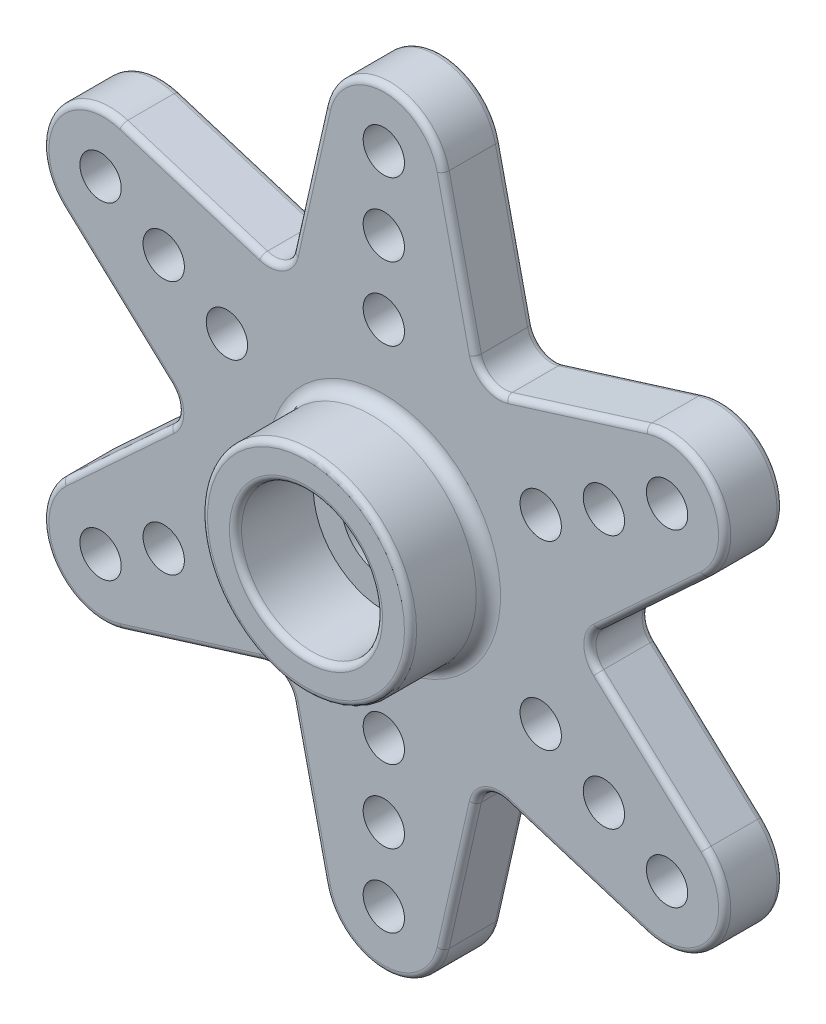
from build123d import *

# Parameters (mm, degrees)
SKETCH1_R                    = 1.75
BOSS_EXTRUDE1_DEPTH          = 2.4
SKETCH2_R                    = 4.3
SKETCH2_R_2                  = 2.9
BOSS_EXTRUDE2_DEPTH          = 3.2
SKETCH4_R                    = 3.6
SKETCH4_R_2                  = 3.3
BOSS_EXTRUDE3_DEPTH          = 0.2
SKETCH5_R                    = 4
SKETCH5_R_2                  = 3.6
SKETCH5_R_3                  = 3.3
CUT_EXTRUDE2_DEPTH           = 0.4
SKETCH6_R                    = 0.85
CUT_EXTRUDE3_DEPTH           = 22.851960767
LPATTERN1_COUNT              = 3
LPATTERN1_PITCH              = 3
CIRPATTERN1_COUNT            = 6
CIRPATTERN1_COPY_1_SKETCH_R  = 0.85
CIRPATTERN1_COPY_1_DEPTH     = 22.851960767
CIRPATTERN1_COPY_2_SKETCH_R  = 0.85
CIRPATTERN1_COPY_2_DEPTH     = 22.851960767
CIRPATTERN1_COPY_3_SKETCH_R  = 0.85
CIRPATTERN1_COPY_3_DEPTH     = 22.851960767
CIRPATTERN1_COPY_4_SKETCH_R  = 0.85
CIRPATTERN1_COPY_4_DEPTH     = 22.851960767
CIRPATTERN1_COPY_5_SKETCH_R  = 0.85
CIRPATTERN1_COPY_5_DEPTH     = 22.851960767
CIRPATTERN1_COPY_6_SKETCH_R  = 0.85
CIRPATTERN1_COPY_6_DEPTH     = 22.851960767
CIRPATTERN1_COPY_7_SKETCH_R  = 0.85
CIRPATTERN1_COPY_7_DEPTH     = 22.851960767
CIRPATTERN1_COPY_8_SKETCH_R  = 0.85
CIRPATTERN1_COPY_8_DEPTH     = 22.851960767
CIRPATTERN1_COPY_9_SKETCH_R  = 0.85
CIRPATTERN1_COPY_9_DEPTH     = 22.851960767
CIRPATTERN1_COPY_10_SKETCH_R = 0.85
CIRPATTERN1_COPY_10_DEPTH    = 22.851960767
FILLET3_R                    = 1
FILLET1_R                    = 0.25
FILLET2_R                    = 0.5


with BuildPart() as part:
    # Sketch1 → Boss-Extrude1 (new body)
    with BuildSketch(Plane.XY):
        with BuildLine():
            Line((-4, -6.92820323), (-2.438733851, -13.850070181))
            ThreePointArc((-2.438733851, -13.850070181), (0, -15.8), (2.438733851, -13.850070181))
            Line((2.438733851, -13.850070181), (4, -6.92820323))
            Line((4, -6.92820323), (10.775145696, -9.037040559))
            ThreePointArc((10.775145696, -9.037040559), (13.68320138, -7.9), (13.213879547, -4.813029623))
            Line((13.213879547, -4.813029623), (8, 0))
            Line((8, 0), (13.213879547, 4.813029623))
            ThreePointArc((13.213879547, 4.813029623), (13.68320138, 7.9), (10.775145696, 9.037040559))
            Line((10.775145696, 9.037040559), (4, 6.92820323))
            Line((4, 6.92820323), (2.438733851, 13.850070181))
            ThreePointArc((2.438733851, 13.850070181), (0, 15.8), (-2.438733851, 13.850070181))
            Line((-2.438733851, 13.850070181), (-4, 6.92820323))
            Line((-4, 6.92820323), (-10.775145696, 9.037040559))
            ThreePointArc((-10.775145696, 9.037040559), (-13.68320138, 7.9), (-13.213879547, 4.813029623))
            Line((-13.213879547, 4.813029623), (-8, 0))
            Line((-8, 0), (-13.213879547, -4.813029623))
            ThreePointArc((-13.213879547, -4.813029623), (-13.68320138, -7.9), (-10.775145696, -9.037040559))
            Line((-10.775145696, -9.037040559), (-4, -6.92820323))
        make_face()
        Circle(SKETCH1_R, mode=Mode.SUBTRACT)
    extrude(amount=BOSS_EXTRUDE1_DEPTH)

    # Sketch2 → Boss-Extrude2 (add)
    with BuildSketch(Plane.XY.offset(2.4)):
        with Locations(Location((0, 0, 0), (0, 0, 180))):
            Circle(SKETCH2_R)
        Circle(SKETCH2_R_2, mode=Mode.SUBTRACT)
    extrude(amount=BOSS_EXTRUDE2_DEPTH)

    # Sketch4 → Boss-Extrude3 (add)
    with BuildSketch(Plane(origin=(0, 0, 0), x_dir=(-1, 0, 0), z_dir=(0, 0, -1))):
        Circle(SKETCH4_R)
        Circle(SKETCH4_R_2, mode=Mode.SUBTRACT)
    extrude(amount=BOSS_EXTRUDE3_DEPTH)

    # Sketch5 → Cut-Extrude2 (cut)
    with BuildSketch(Plane(origin=(0, 0, 0), x_dir=(-1, 0, 0), z_dir=(0, 0, -1))):
        Circle(SKETCH5_R)
        Circle(SKETCH5_R_2, mode=Mode.SUBTRACT)
        Circle(SKETCH5_R_3)
    extrude(amount=-CUT_EXTRUDE2_DEPTH, mode=Mode.SUBTRACT)

    # Sketch6 → Cut-Extrude3 (cut, through all)
    with BuildSketch(Plane(origin=(0, 0, 0), x_dir=(-1, 0, 0), z_dir=(0, 0, -1))):
        with Locations((0, 7.45)):
            Circle(SKETCH6_R)
    cut_extrude3 = extrude(amount=-CUT_EXTRUDE3_DEPTH, mode=Mode.SUBTRACT)

    # LPattern1: Cut-Extrude3 ×3
    with Locations(*[(0, i * LPATTERN1_PITCH, 0) for i in range(1, LPATTERN1_COUNT)]):
        add(cut_extrude3, mode=Mode.SUBTRACT)

    # CirPattern1: Cut-Extrude3 ×6 about axis
    cirpattern1_axis = Axis((0, 0, 0), (0, 0, 1))
    for i in range(1, CIRPATTERN1_COUNT):
        add(cut_extrude3.rotate(cirpattern1_axis, i * 360 / CIRPATTERN1_COUNT), mode=Mode.SUBTRACT)

    # CirPattern1 copy 1 sketch → CirPattern1 copy 1 (cut, through all)
    with BuildSketch(Plane(origin=(-2.598076211, 1.5, 0), x_dir=(-0.5000000000000001, -0.8660254037844386, 0), z_dir=(0, 0, -1))):
        with Locations((0, 7.45)):
            Circle(CIRPATTERN1_COPY_1_SKETCH_R)
    extrude(amount=-CIRPATTERN1_COPY_1_DEPTH, mode=Mode.SUBTRACT)

    # CirPattern1 copy 2 sketch → CirPattern1 copy 2 (cut, through all)
    with BuildSketch(Plane(origin=(-2.598076211, -1.5, 0), x_dir=(0.4999999999999998, -0.8660254037844387, 0), z_dir=(0, 0, -1))):
        with Locations((0, 7.45)):
            Circle(CIRPATTERN1_COPY_2_SKETCH_R)
    extrude(amount=-CIRPATTERN1_COPY_2_DEPTH, mode=Mode.SUBTRACT)

    # CirPattern1 copy 3 sketch → CirPattern1 copy 3 (cut, through all)
    with BuildSketch(Plane(origin=(0, -3, 0), x_dir=(1, 0, 0), z_dir=(0, 0, -1))):
        with Locations((0, 7.45)):
            Circle(CIRPATTERN1_COPY_3_SKETCH_R)
    extrude(amount=-CIRPATTERN1_COPY_3_DEPTH, mode=Mode.SUBTRACT)

    # CirPattern1 copy 4 sketch → CirPattern1 copy 4 (cut, through all)
    with BuildSketch(Plane(origin=(2.598076211, -1.5, 0), x_dir=(0.5000000000000004, 0.8660254037844384, 0), z_dir=(0, 0, -1))):
        with Locations((0, 7.45)):
            Circle(CIRPATTERN1_COPY_4_SKETCH_R)
    extrude(amount=-CIRPATTERN1_COPY_4_DEPTH, mode=Mode.SUBTRACT)

    # CirPattern1 copy 5 sketch → CirPattern1 copy 5 (cut, through all)
    with BuildSketch(Plane(origin=(2.598076211, 1.5, 0), x_dir=(-0.5000000000000001, 0.8660254037844386, 0), z_dir=(0, 0, -1))):
        with Locations((0, 7.45)):
            Circle(CIRPATTERN1_COPY_5_SKETCH_R)
    extrude(amount=-CIRPATTERN1_COPY_5_DEPTH, mode=Mode.SUBTRACT)

    # CirPattern1 copy 6 sketch → CirPattern1 copy 6 (cut, through all)
    with BuildSketch(Plane(origin=(-5.196152423, 3, 0), x_dir=(-0.5000000000000001, -0.8660254037844386, 0), z_dir=(0, 0, -1))):
        with Locations((0, 7.45)):
            Circle(CIRPATTERN1_COPY_6_SKETCH_R)
    extrude(amount=-CIRPATTERN1_COPY_6_DEPTH, mode=Mode.SUBTRACT)

    # CirPattern1 copy 7 sketch → CirPattern1 copy 7 (cut, through all)
    with BuildSketch(Plane(origin=(-5.196152423, -3, 0), x_dir=(0.4999999999999998, -0.8660254037844387, 0), z_dir=(0, 0, -1))):
        with Locations((0, 7.45)):
            Circle(CIRPATTERN1_COPY_7_SKETCH_R)
    extrude(amount=-CIRPATTERN1_COPY_7_DEPTH, mode=Mode.SUBTRACT)

    # CirPattern1 copy 8 sketch → CirPattern1 copy 8 (cut, through all)
    with BuildSketch(Plane(origin=(0, -6, 0), x_dir=(1, 0, 0), z_dir=(0, 0, -1))):
        with Locations((0, 7.45)):
            Circle(CIRPATTERN1_COPY_8_SKETCH_R)
    extrude(amount=-CIRPATTERN1_COPY_8_DEPTH, mode=Mode.SUBTRACT)

    # CirPattern1 copy 9 sketch → CirPattern1 copy 9 (cut, through all)
    with BuildSketch(Plane(origin=(5.196152423, -3, 0), x_dir=(0.5000000000000004, 0.8660254037844384, 0), z_dir=(0, 0, -1))):
        with Locations((0, 7.45)):
            Circle(CIRPATTERN1_COPY_9_SKETCH_R)
    extrude(amount=-CIRPATTERN1_COPY_9_DEPTH, mode=Mode.SUBTRACT)

    # CirPattern1 copy 10 sketch → CirPattern1 copy 10 (cut, through all)
    with BuildSketch(Plane(origin=(5.196152423, 3, 0), x_dir=(-0.5000000000000001, 0.8660254037844386, 0), z_dir=(0, 0, -1))):
        with Locations((0, 7.45)):
            Circle(CIRPATTERN1_COPY_10_SKETCH_R)
    extrude(amount=-CIRPATTERN1_COPY_10_DEPTH, mode=Mode.SUBTRACT)

    # Fillet3
    fillet3_edges = [part.edges().sort_by_distance(p)[0] for p in [
        (4, 6.92820323, 1.2),
        (8, 0, 1.2),
        (4, -6.92820323, 1.2),
        (-4, -6.92820323, 1.2),
        (-8, 0, 1.2),
        (-4, 6.92820323, 1.2),
    ]]
    fillet(fillet3_edges, radius=FILLET3_R)

    # Fillet1
    fillet1_edges = [part.edges().sort_by_distance(p)[0] for p in [
        (-13.68320138, 7.9, 2.4),
        (-11.004932016, 2.773908887, 2.4),
        (7.904741572, 8.14359625, 0),
        (13.68320138, 7.9, 0),
        (11.004932016, -2.773908887, 0),
        (7.904741572, -8.14359625, 0),
        (7.904741572, -8.14359625, 2.4),
        (13.68320138, -7.9, 0),
        (-3.100190444, -10.917505137, 0),
        (-3.100190444, -10.917505137, 2.4),
        (-11.004932016, -2.773908887, 0),
        (-11.004932016, -2.773908887, 2.4),
        (-7.904741572, 8.14359625, 0),
        (-7.904741572, 8.14359625, 2.4),
        (3.100190444, 10.917505137, 0),
        (3.100190444, -10.917505137, 0),
        (3.100190444, 10.917505137, 2.4),
        (11.004932016, 2.773908887, 0),
        (11.004932016, 2.773908887, 2.4),
        (0, -15.8, 0),
        (4.237140578, -7.338942761, 0),
        (4.237140578, -7.338942761, 2.4),
        (-4.237140578, -7.338942761, 0),
        (-4.237140578, -7.338942761, 2.4),
        (-8.474281157, 0, 0),
        (-8.474281157, 0, 2.4),
        (-4.237140578, 7.338942761, 0),
        (-4.237140578, 7.338942761, 2.4),
        (4.237140578, 7.338942761, 0),
        (4.237140578, 7.338942761, 2.4),
        (8.474281157, 0, 0),
        (8.474281157, 0, 2.4),
        (-7.904741572, -8.14359625, 0),
        (-13.68320138, -7.9, 0),
        (-11.004932016, 2.773908887, 0),
        (-13.68320138, 7.9, 0),
        (-13.68320138, -7.9, 2.4),
        (-3.100190444, 10.917505137, 0),
        (0, 15.8, 0),
        (-7.904741572, -8.14359625, 2.4),
        (0, -15.8, 2.4),
        (3.100190444, -10.917505137, 2.4),
        (0, 15.8, 2.4),
        (13.68320138, -7.9, 2.4),
        (11.004932016, -2.773908887, 2.4),
        (13.68320138, 7.9, 2.4),
        (7.904741572, 8.14359625, 2.4),
        (4.3, 0, 5.6),
        (-2.9, 0, 5.6),
        (-3.100190444, 10.917505137, 2.4),
    ]]
    fillet(fillet1_edges, radius=FILLET1_R)

    # Fillet2
    fillet2_edges = [part.edges().sort_by_distance(p)[0] for p in [
        (4.3, 0, 2.4),
    ]]
    fillet(fillet2_edges, radius=FILLET2_R)


solid = part.part
